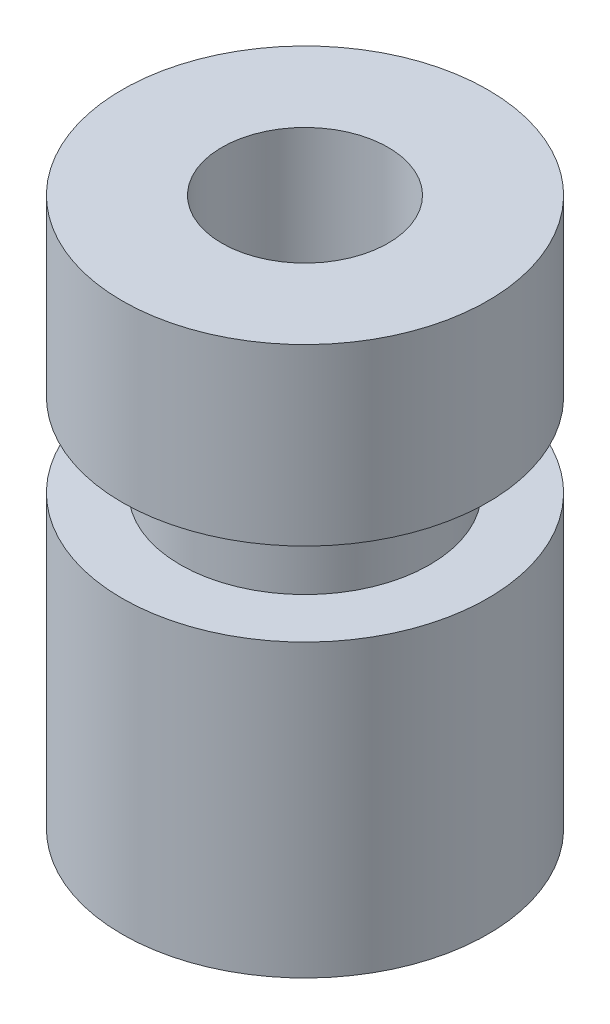
from build123d import *


with BuildPart() as part:
    # 草图2 → 旋转1 (revolve)
    with BuildSketch(Plane.XY):
        Polygon((1, 6.6), (1, 0), (2.2, 0), (2.2, 3.5), (1.5, 3.5), (1.5, 4.5), (2.2, 4.5), (2.2, 6.6), align=None)
    revolve(axis=Axis((0, 1.745283019, 0), (0, -1, 0)))


solid = part.part
